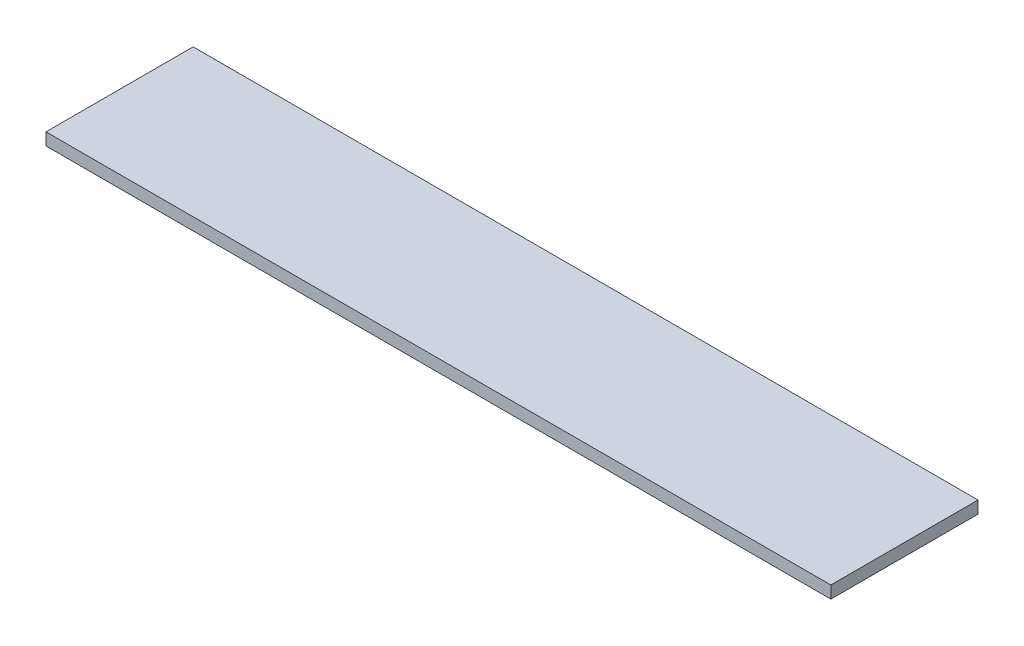
from build123d import *

# Parameters (mm, degrees)
SKETCH1_W           = 406.4
SKETCH1_H           = 76.2
BOSS_EXTRUDE1_DEPTH = 6.35


with BuildPart() as part:
    # Sketch1 → Boss-Extrude1 (new body)
    with BuildSketch(Plane(origin=(0, 0, 0), x_dir=(1, 0, 0), z_dir=(0, 1, 0))):
        with Locations((203.2, 38.1)):
            Rectangle(SKETCH1_W, SKETCH1_H)
    extrude(amount=BOSS_EXTRUDE1_DEPTH)


solid = part.part
